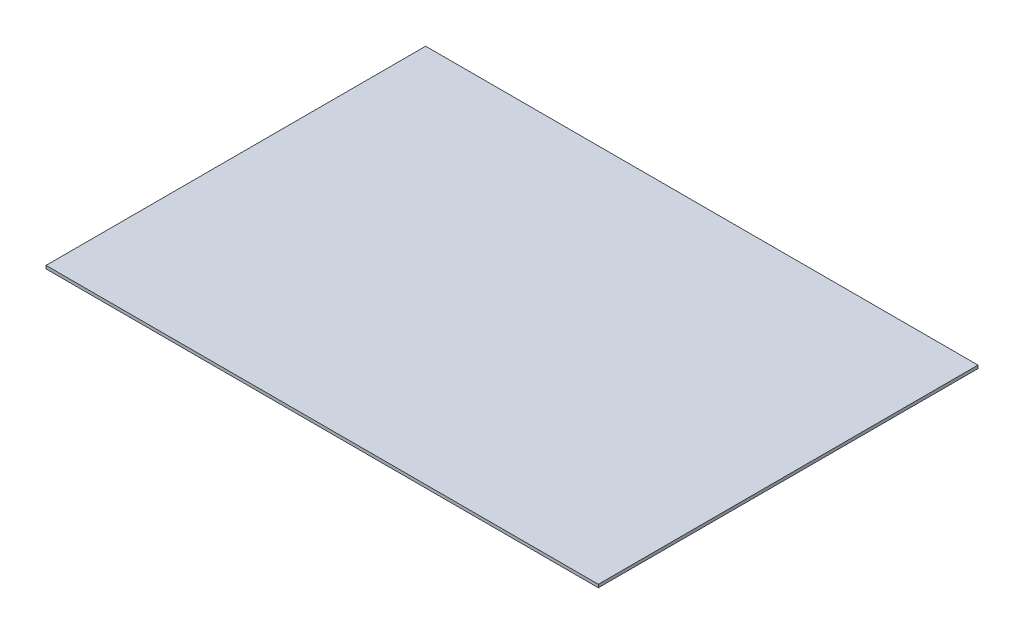
from build123d import *

# Parameters (mm, degrees)
SKETCH1_W           = 362.14
SKETCH1_H           = 248.92
BOSS_EXTRUDE1_DEPTH = 2


with BuildPart() as part:
    # Sketch1 → Boss-Extrude1 (new body)
    with BuildSketch(Plane(origin=(0, 0, 0), x_dir=(1, 0, 0), z_dir=(0, 1, 0))):
        with Locations((181.07, 124.46)):
            Rectangle(SKETCH1_W, SKETCH1_H)
    extrude(amount=BOSS_EXTRUDE1_DEPTH)


solid = part.part
